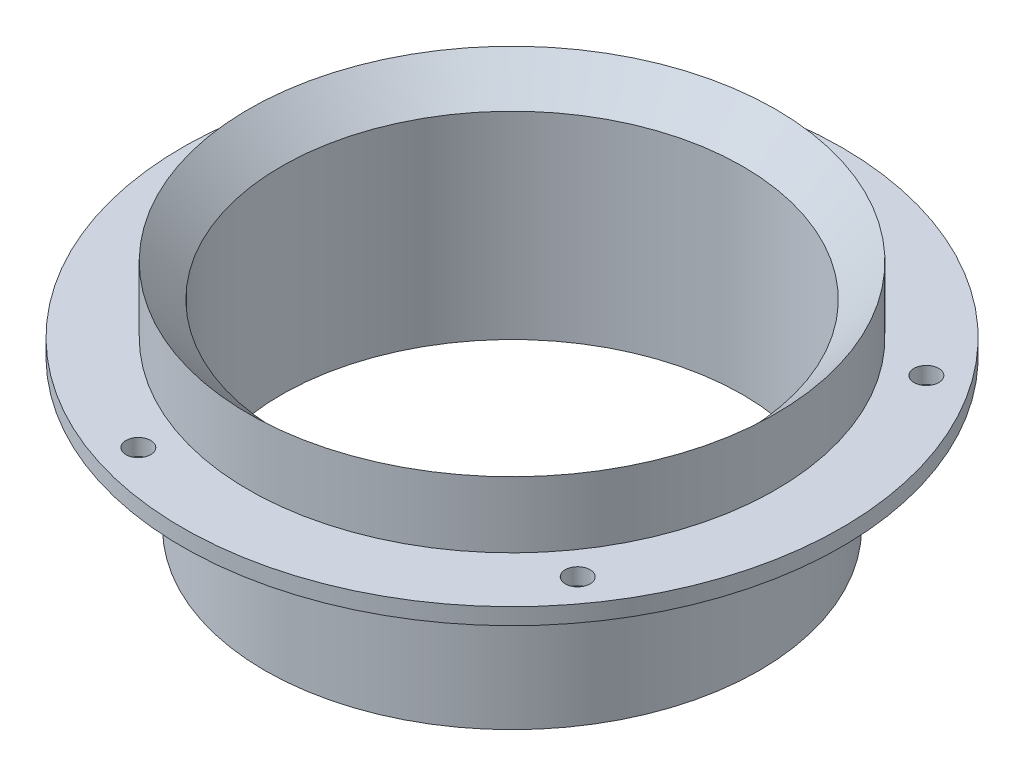
from build123d import *

# Parameters (mm, degrees)
HOLE1_D           = 9.525
CIRPATTERN1_COUNT = 5


with BuildPart() as part:
    # Sketch2 → Revolve1 (revolve)
    with BuildSketch(Plane.XY):
        Polygon((-88.9, 0), (-95.25, 0), (-95.25, 57.15), (-127, 57.15), (-127, 63.5), (-101.6, 63.5), (-101.6, 88.9), (-88.9, 76.2), align=None)
    revolve(axis=Axis((0, 3.725942355, 0), (0, 1, 0)))

    # Hole1 (through all)
    with Locations(Plane(origin=(0, 63.5, 0), x_dir=(1, 0, 0), z_dir=(0, 1, 0))):
        with Locations((-114.3, 0)):
            hole1 = Hole(HOLE1_D / 2)

    # CirPattern1: Hole1 ×5 about axis
    cirpattern1_axis = Axis((0, 0, 0), (0, 1, 0))
    for i in range(1, CIRPATTERN1_COUNT):
        add(hole1.rotate(cirpattern1_axis, i * 360 / CIRPATTERN1_COUNT), mode=Mode.SUBTRACT)


solid = part.part
